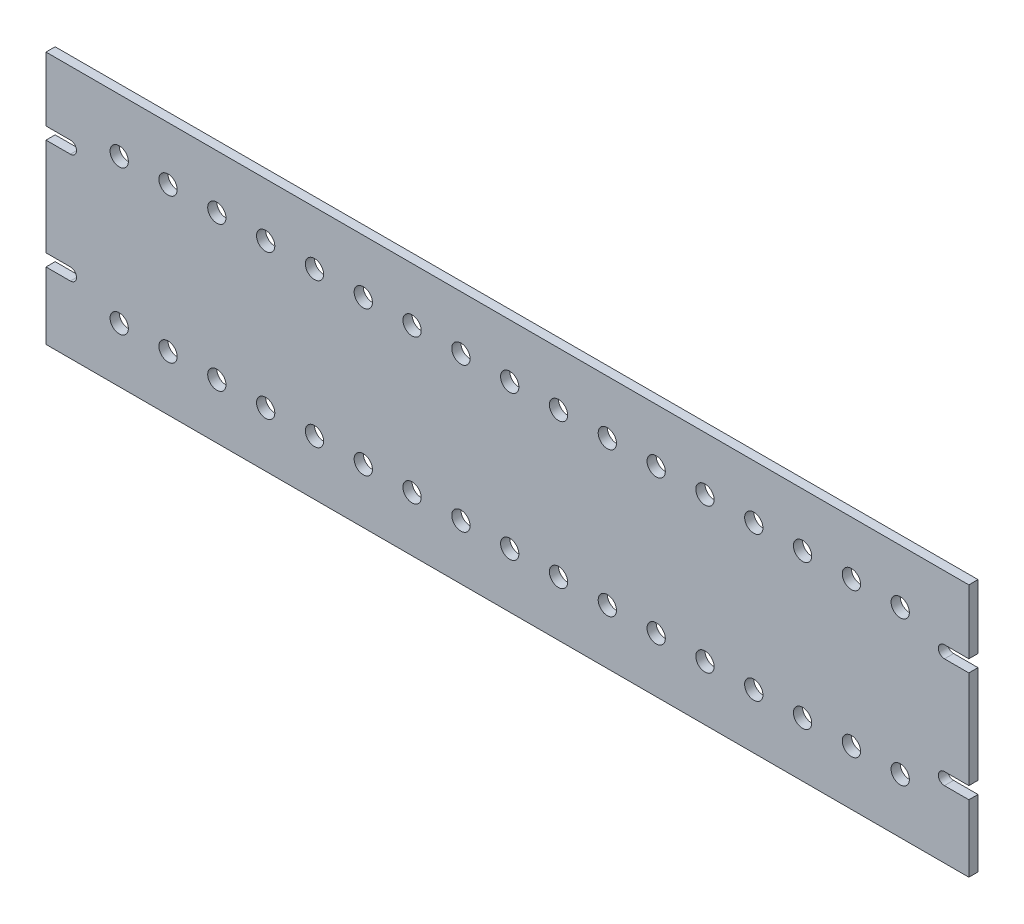
from build123d import *

# Parameters (mm, degrees)
SKETCH1_R           = 4.7625
BOSS_EXTRUDE1_DEPTH = 4.7625


with BuildPart() as part:
    # Sketch1 → Boss-Extrude1 (new body)
    with BuildSketch(Plane.XY):
        with BuildLine():
            Line((0, 98.425), (12.7, 98.425))
            ThreePointArc((12.7, 98.425), (15.875, 95.25), (12.7, 92.075))
            Line((12.7, 92.075), (0, 92.075))
            Line((0, 92.075), (0, 41.275))
            Line((0, 41.275), (12.7, 41.275))
            ThreePointArc((12.7, 41.275), (15.875, 38.1), (12.7, 34.925))
            Line((12.7, 34.925), (0, 34.925))
            Line((0, 34.925), (0, 0))
            Line((0, 0), (480.21875, 0))
            Line((480.21875, 0), (480.21875, 34.925))
            Line((480.21875, 34.925), (467.51875, 34.925))
            ThreePointArc((467.51875, 34.925), (464.34375, 38.1), (467.51875, 41.275))
            Line((467.51875, 41.275), (480.21875, 41.275))
            Line((480.21875, 41.275), (480.21875, 92.075))
            Line((480.21875, 92.075), (467.51875, 92.075))
            ThreePointArc((467.51875, 92.075), (464.34375, 95.25), (467.51875, 98.425))
            Line((467.51875, 98.425), (480.21875, 98.425))
            Line((480.21875, 98.425), (480.21875, 131.7625))
            Line((480.21875, 131.7625), (0, 131.7625))
            Line((0, 131.7625), (0, 98.425))
        make_face()
        with Locations((38.1, 103.82449821)):
            Circle(SKETCH1_R, mode=Mode.SUBTRACT)
        with Locations((38.1, 28.575703441)):
            Circle(SKETCH1_R, mode=Mode.SUBTRACT)
        with Locations((63.5, 103.82449821)):
            Circle(SKETCH1_R, mode=Mode.SUBTRACT)
        with Locations((63.5, 28.575703441)):
            Circle(SKETCH1_R, mode=Mode.SUBTRACT)
        with Locations((88.9, 103.82449821)):
            Circle(SKETCH1_R, mode=Mode.SUBTRACT)
        with Locations((88.9, 28.575703441)):
            Circle(SKETCH1_R, mode=Mode.SUBTRACT)
        with Locations((114.3, 103.82449821)):
            Circle(SKETCH1_R, mode=Mode.SUBTRACT)
        with Locations((114.3, 28.575703441)):
            Circle(SKETCH1_R, mode=Mode.SUBTRACT)
        with Locations((139.7, 103.82449821)):
            Circle(SKETCH1_R, mode=Mode.SUBTRACT)
        with Locations((139.7, 28.575703441)):
            Circle(SKETCH1_R, mode=Mode.SUBTRACT)
        with Locations((165.1, 103.82449821)):
            Circle(SKETCH1_R, mode=Mode.SUBTRACT)
        with Locations((165.1, 28.575703441)):
            Circle(SKETCH1_R, mode=Mode.SUBTRACT)
        with Locations((190.5, 103.82449821)):
            Circle(SKETCH1_R, mode=Mode.SUBTRACT)
        with Locations((190.5, 28.575703441)):
            Circle(SKETCH1_R, mode=Mode.SUBTRACT)
        with Locations((215.9, 103.82449821)):
            Circle(SKETCH1_R, mode=Mode.SUBTRACT)
        with Locations((215.9, 28.575703441)):
            Circle(SKETCH1_R, mode=Mode.SUBTRACT)
        with Locations((241.3, 103.82449821)):
            Circle(SKETCH1_R, mode=Mode.SUBTRACT)
        with Locations((241.3, 28.575703441)):
            Circle(SKETCH1_R, mode=Mode.SUBTRACT)
        with Locations((266.7, 103.82449821)):
            Circle(SKETCH1_R, mode=Mode.SUBTRACT)
        with Locations((266.7, 28.575703441)):
            Circle(SKETCH1_R, mode=Mode.SUBTRACT)
        with Locations((292.1, 103.82449821)):
            Circle(SKETCH1_R, mode=Mode.SUBTRACT)
        with Locations((292.1, 28.575703441)):
            Circle(SKETCH1_R, mode=Mode.SUBTRACT)
        with Locations((317.5, 103.82449821)):
            Circle(SKETCH1_R, mode=Mode.SUBTRACT)
        with Locations((317.5, 28.575703441)):
            Circle(SKETCH1_R, mode=Mode.SUBTRACT)
        with Locations((342.9, 103.82449821)):
            Circle(SKETCH1_R, mode=Mode.SUBTRACT)
        with Locations((342.9, 28.575703441)):
            Circle(SKETCH1_R, mode=Mode.SUBTRACT)
        with Locations((368.3, 103.82449821)):
            Circle(SKETCH1_R, mode=Mode.SUBTRACT)
        with Locations((368.3, 28.575703441)):
            Circle(SKETCH1_R, mode=Mode.SUBTRACT)
        with Locations((393.7, 103.82449821)):
            Circle(SKETCH1_R, mode=Mode.SUBTRACT)
        with Locations((393.7, 28.575703441)):
            Circle(SKETCH1_R, mode=Mode.SUBTRACT)
        with Locations((419.1, 103.82449821)):
            Circle(SKETCH1_R, mode=Mode.SUBTRACT)
        with Locations((419.1, 28.575703441)):
            Circle(SKETCH1_R, mode=Mode.SUBTRACT)
        with Locations((444.5, 103.82449821)):
            Circle(SKETCH1_R, mode=Mode.SUBTRACT)
        with Locations((444.5, 28.575703441)):
            Circle(SKETCH1_R, mode=Mode.SUBTRACT)
    extrude(amount=BOSS_EXTRUDE1_DEPTH)


solid = part.part
